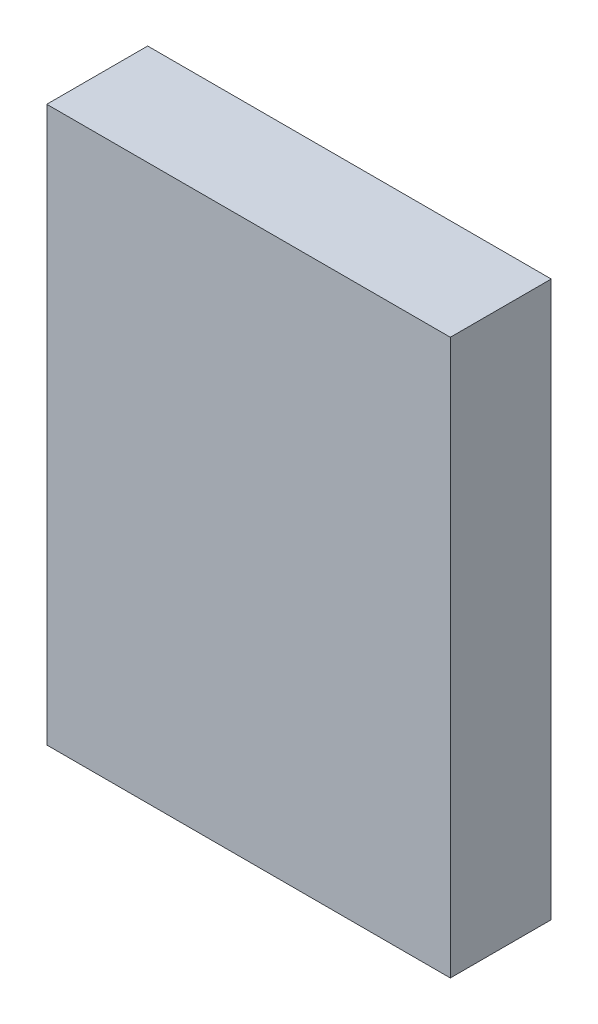
from build123d import *

# Parameters (mm, degrees)
SKETCH1_W           = 20
SKETCH1_H           = 27.5
BOSS_EXTRUDE1_DEPTH = 5


with BuildPart() as part:
    # Sketch1 → Boss-Extrude1 (new body)
    with BuildSketch(Plane.XY):
        Rectangle(SKETCH1_W, SKETCH1_H)
    extrude(amount=BOSS_EXTRUDE1_DEPTH)


solid = part.part
